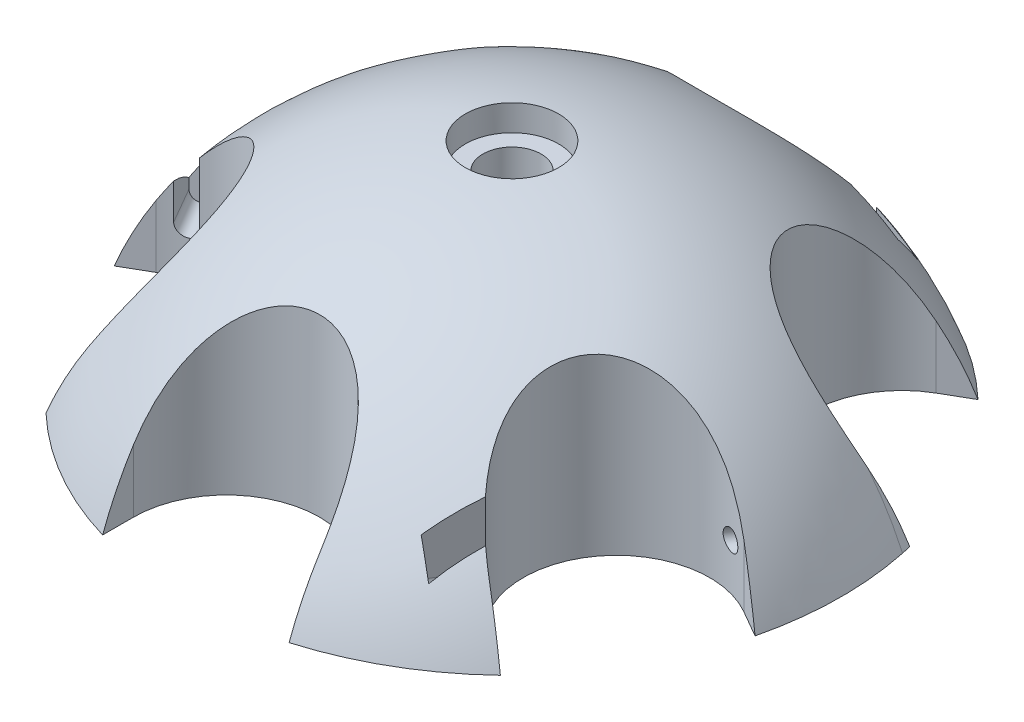
from build123d import *

# Parameters (mm, degrees)
SKETCH2_R           = 80.052532967
CUT_EXTRUDE1_DEPTH  = 81
CUT_EXTRUDE2_DEPTH  = 41
CIRPATTERN1_COUNT   = 6
CUT_EXTRUDE3_START  = -3
SKETCH7_R           = 1.75
CUT_EXTRUDE3_DEPTH  = 42
CUT_EXTRUDE5_DEPTH  = 23
CIRPATTERN2_COUNT   = 3
SKETCH14_R          = 8
CUT_EXTRUDE8_DEPTH  = 5
BOSS_EXTRUDE1_DEPTH = 4
SKETCH13_R          = 5
CUT_EXTRUDE7_DEPTH  = 45


with BuildPart() as part:
    # Sketch1 → Revolve1 (revolve)
    with BuildSketch(Plane.XY):
        with BuildLine():
            Line((0, 60), (0, -60))
            ThreePointArc((0, -60), (-60, 0), (0, 60))
        make_face()
    revolve(axis=Axis((0, 60, 0), (0, -1, 0)))

    # Sketch2 → Cut-Extrude1 (cut, through all)
    with BuildSketch(Plane(origin=(0, 20, 0), x_dir=(1, 0, 0), z_dir=(0, 1, 0))):
        Circle(SKETCH2_R)
    extrude(amount=-CUT_EXTRUDE1_DEPTH, mode=Mode.SUBTRACT)

    # Sketch6 → Cut-Extrude2 (cut, through all)
    with BuildSketch(Plane.XZ.offset(-20)):
        with BuildLine():
            Line((-34.426406871, 38.351303888), (-45.706213322, 44.863703179))
            Line((-45.706213322, 44.863703179), (-61.706213322, 17.150890258))
            Line((-61.706213322, 17.150890258), (-50.426406871, 10.638490967))
            ThreePointArc((-50.426406871, 10.638490967), (-28.570000411, 16.494897428), (-34.426406871, 38.351303888))
        make_face()
    cut_extrude2 = extrude(amount=-CUT_EXTRUDE2_DEPTH, mode=Mode.SUBTRACT)

    # CirPattern1: Cut-Extrude2 ×6 about axis
    cirpattern1_axis = Axis((0, 0, 0), (0, 1, 0))
    for i in range(1, CIRPATTERN1_COUNT):
        add(cut_extrude2.rotate(cirpattern1_axis, i * 360 / CIRPATTERN1_COUNT), mode=Mode.SUBTRACT)

    # Sketch7 → Cut-Extrude3 (cut)
    with BuildSketch(Plane(origin=(8, 0, 13.856406461), x_dir=(-0.866025404, 0, 0.5), z_dir=(-0.5, 0, -0.866025404)).offset(CUT_EXTRUDE3_START)):
        with Locations((45, 28)):
            Circle(SKETCH7_R)
    cut_extrude3 = extrude(amount=CUT_EXTRUDE3_DEPTH, mode=Mode.SUBTRACT)

    # Sketch11 → Cut-Extrude5 (cut)
    with BuildSketch(Plane(origin=(0, 0, 0), x_dir=(-0.866025404, 0, 0.5), z_dir=(-0.5, 0, -0.866025404))):
        with BuildLine():
            Line((46.75, 28), (46.75, 40.645857748))
            Line((46.75, 40.645857748), (43.25, 40.645857748))
            Line((43.25, 40.645857748), (43.25, 28))
            ThreePointArc((43.25, 28), (45, 26.25), (46.75, 28))
        make_face()
    cut_extrude5 = extrude(amount=CUT_EXTRUDE5_DEPTH, mode=Mode.SUBTRACT)

    # CirPattern2: Cut-Extrude3, Cut-Extrude5 ×3 about axis
    cirpattern2_axis = Axis((0, 0, 0), (0, 1, 0))
    for i in range(1, CIRPATTERN2_COUNT):
        add(cut_extrude3.rotate(cirpattern2_axis, i * 360 / CIRPATTERN2_COUNT), mode=Mode.SUBTRACT)
        add(cut_extrude5.rotate(cirpattern2_axis, i * 360 / CIRPATTERN2_COUNT), mode=Mode.SUBTRACT)

    # Sketch14 → Cut-Extrude8 (cut)
    with BuildSketch(Plane(origin=(0, 60, 0), x_dir=(1, 0, 0), z_dir=(0, 1, 0))):
        Circle(SKETCH14_R)
    extrude(amount=-CUT_EXTRUDE8_DEPTH, mode=Mode.SUBTRACT)

    # Sketch12 → Boss-Extrude1 (add)
    with BuildSketch(Plane.XZ.offset(-20)):
        Polygon((15.588457268, -27), (31.176914536, 0), (15.588457268, 27), (-15.588457268, 27), (-31.176914536, 0), (-15.588457268, -27), align=None)
    extrude(amount=BOSS_EXTRUDE1_DEPTH)

    # Sketch13 → Cut-Extrude7 (cut, through all)
    with BuildSketch(Plane(origin=(0, 60, 0), x_dir=(1, 0, 0), z_dir=(0, 1, 0))):
        Circle(SKETCH13_R)
    extrude(amount=-CUT_EXTRUDE7_DEPTH, mode=Mode.SUBTRACT)


solid = part.part
